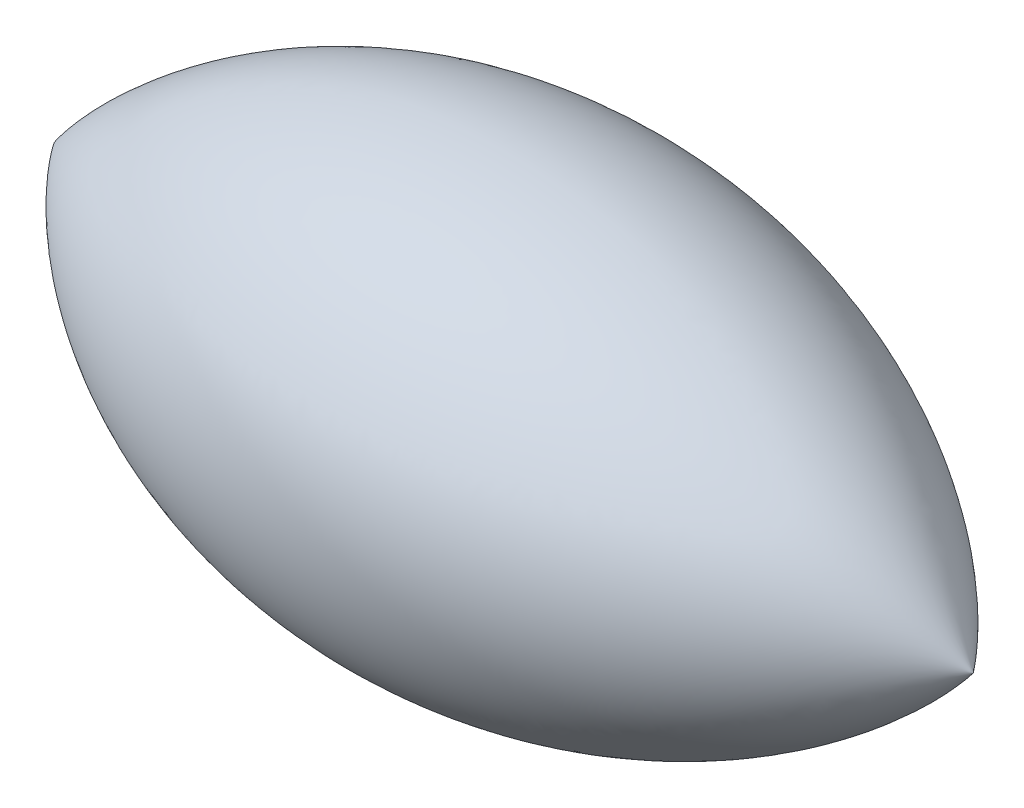
from build123d import *


with BuildPart() as part:
    # Sketch1 → Revolve1 (revolve)
    with BuildSketch(Plane.XY):
        with BuildLine():
            Line((-419.657652671, 142.961048383), (451.481014066, 142.961048383))
            add(Edge.make_bspline(
                [(-419.657652671, 142.961048383), (-209.010294926, 427.717688684), (237.057590631, 411.03910721), (451.481014066, 142.961048383)],
                knots=[0, 0, 0, 0, 1, 1, 1, 1], degree=3))
        make_face()
    revolve(axis=Axis((-419.657652671, 142.961048383, 0), (1, 0, 0)))


solid = part.part
